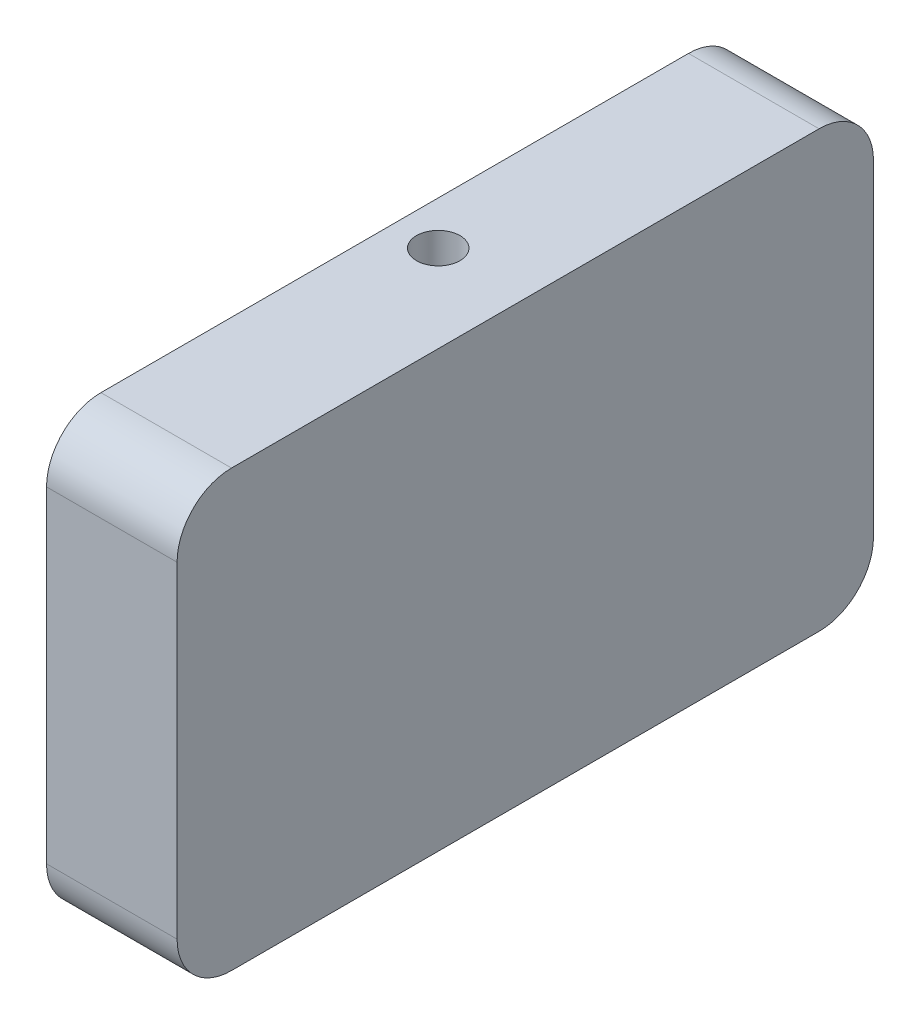
from build123d import *

# Parameters (mm, degrees)
EXTRUDE_1_DEPTH     = 12
SKETCH_2_R          = 7
CUT_EXTRUDE_1_DEPTH = 8
SKETCH_5_R          = 2
CUT_EXTRUDE_2_DEPTH = 41


with BuildPart() as part:
    # 草图1 → 凸台-拉伸1 (new body)
    with BuildSketch(Plane(origin=(0, 0, 0), x_dir=(0, 0, -1), z_dir=(1, 0, 0))):
        with BuildLine():
            Line((-27, 20), (27, 20))
            ThreePointArc((27, 20), (30.535533906, 18.535533906), (32, 15))
            Line((32, 15), (32, -15))
            ThreePointArc((32, -15), (30.535533906, -18.535533906), (27, -20))
            Line((27, -20), (-27, -20))
            ThreePointArc((-27, -20), (-30.535533906, -18.535533906), (-32, -15))
            Line((-32, -15), (-32, 15))
            ThreePointArc((-32, 15), (-30.535533906, 18.535533906), (-27, 20))
        make_face()
    extrude(amount=EXTRUDE_1_DEPTH)

    # 草图2 → 切除-拉伸1 (cut)
    with BuildSketch(Plane.ZY):
        Circle(SKETCH_2_R)
    extrude(amount=-CUT_EXTRUDE_1_DEPTH, mode=Mode.SUBTRACT)

    # 草图5 → 切除-拉伸2 (cut, through all)
    with BuildSketch(Plane.XZ.offset(20)):
        with Locations((4, 0)):
            Circle(SKETCH_5_R)
    extrude(amount=-CUT_EXTRUDE_2_DEPTH, mode=Mode.SUBTRACT)


solid = part.part
